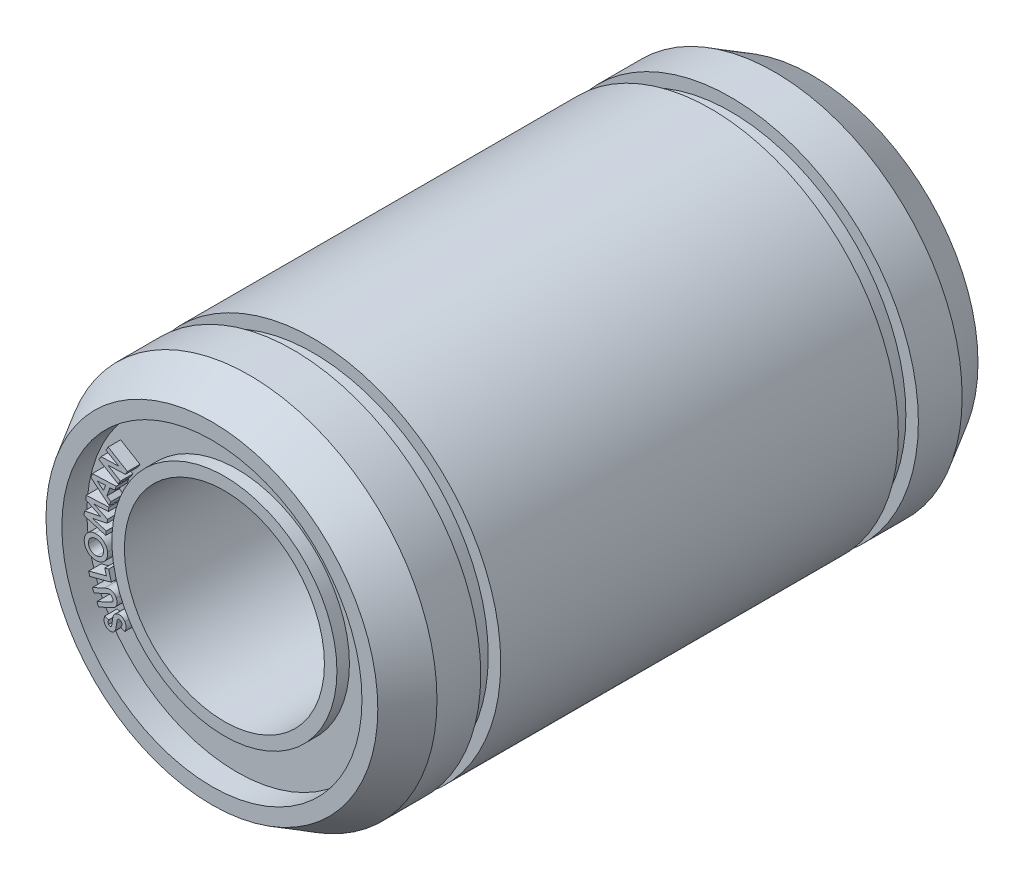
from build123d import *

# Parameters (mm, degrees)
SKETCH1_R                = 7.5
SKETCH1_R_2              = 6
BOSS_EXTRUDE1_DEPTH      = 12
CHAMFER2_SIZE            = 1.5
CHAMFER2_SIZE2           = 0.866025404
SKETCH5_R                = 6
SKETCH5_R_2              = 4
BOSS_EXTRUDE2_DEPTH      = 11
BOSS_EXTRUDE2_DEPTH_BACK = 11
SKETCH6_R                = 4.5
SKETCH6_R_2              = 4
BOSS_EXTRUDE3_DEPTH      = 0.5
SKETCH7_W                = 0.8
SKETCH7_H                = 0.5
BOSS_EXTRUDE4_DEPTH      = 0.5
CHAMFER3_SIZE            = 1.5
CHAMFER3_SIZE2           = 0.866025404


with BuildPart() as part:
    # Sketch1 → Boss-Extrude1 (new, symmetric)
    with BuildSketch(Plane.XY):
        Circle(SKETCH1_R)
        Circle(SKETCH1_R_2, mode=Mode.SUBTRACT)
    extrude(amount=BOSS_EXTRUDE1_DEPTH, both=True)

    # Chamfer2
    chamfer2_edges = [part.edges().sort_by_distance(p)[0] for p in [
        (-7.5, 0, 12),
    ]]
    chamfer2_side = [part.faces().sort_by_distance(p)[0] for p in [
        (-7.5, 0, 0),
    ]]
    chamfer(chamfer2_edges, length=CHAMFER2_SIZE, length2=CHAMFER2_SIZE2, reference=chamfer2_side[0])



with BuildPart() as body_2:
    # Sketch5 → Boss-Extrude2 (new, two sides)
    with BuildSketch(Plane.XY) as boss_extrude2_sk:
        Circle(SKETCH5_R)
        Circle(SKETCH5_R_2, mode=Mode.SUBTRACT)
    extrude(amount=BOSS_EXTRUDE2_DEPTH)
    extrude(boss_extrude2_sk.sketch, amount=-BOSS_EXTRUDE2_DEPTH_BACK)


with BuildPart() as part_1:
    add(part.part)

    add(body_2.part)  # Boss-Extrude3 merges body 2
    # Sketch6 → Boss-Extrude3 (add)
    with BuildSketch(Plane.XY.offset(11)):
        Circle(SKETCH6_R)
        Circle(SKETCH6_R_2, mode=Mode.SUBTRACT)
    boss_extrude3 = extrude(amount=BOSS_EXTRUDE3_DEPTH)

    # Mirror1: Boss-Extrude3 across plane
    add(boss_extrude3.mirror(Plane.XY))

    # Sketch7 → Cut-Revolve1 (revolve, cut)
    with BuildSketch(Plane(origin=(0, 0, 0), x_dir=(0, 0, -1), z_dir=(1, 0, 0)), mode=Mode.PRIVATE) as cut_revolve1_sk:
        with Locations((-8.35, 7.25)):
            Rectangle(SKETCH7_W, SKETCH7_H)
        with Locations((8.35, 7.25)):
            Rectangle(SKETCH7_W, SKETCH7_H)
    revolve(cut_revolve1_sk.sketch.rotate(Axis((0, 0, 0), (0, 0, -1)), 90), axis=Axis((0, 0, 0), (0, 0, -1)), mode=Mode.SUBTRACT)

    # Sketch8 → Boss-Extrude4 (add)
    with BuildSketch(Plane.XY.offset(11)):
        Polygon((-5.019213926, 2.56696334), (-4.934838926, 2.707408052), (-4.229009599, 2.73336959), (-4.736161041, 3.03805709), (-4.647819695, 3.184811898), (-3.877086522, 2.72165084), (-3.961822099, 2.580665263), (-4.666028829, 2.554523436), (-4.160319695, 2.25055709), (-4.248480752, 2.103802283), align=None)
        Polygon((-5.335912282, 1.78586355), (-5.281104589, 1.949024608), (-4.326296897, 1.9897698), (-4.382546897, 1.822462108), (-4.578881032, 1.815070281), (-4.694986801, 1.470178454), (-4.54390507, 1.342714512), (-4.600335359, 1.175406819), align=None)
        Polygon((-5.084049301, 1.793255377), (-4.831645455, 1.582858742), (-4.756104589, 1.807498166), align=None, mode=Mode.SUBTRACT)
        Polygon((-5.614467681, 0.334474611), (-5.594455662, 0.499618842), (-4.951006143, 0.629787111), (-5.544515758, 0.912479419), (-5.524684028, 1.0752799), (-4.619816239, 1.1174674), (-4.639467681, 0.954666919), (-5.210982104, 0.927263073), (-4.673902778, 0.670892881), (-4.691931624, 0.521974611), (-5.274443643, 0.403344804), (-4.726186431, 0.23856115), (-4.746018162, 0.073957785), align=None)
        with BuildLine():
            add(Edge.make_bspline(
                [(-5.603687751, -0.569841462), (-5.604771213, -0.554405134), (-5.606912505, -0.523897658), (-5.604836323, -0.478508597), (-5.59828654, -0.434375331), (-5.587500583, -0.391434334), (-5.572018329, -0.349792704), (-5.552227666, -0.309321337), (-5.527970554, -0.270163036), (-5.499603183, -0.232735486), (-5.46801183, -0.197899174), (-5.433869548, -0.166445264), (-5.39720005, -0.139279288), (-5.358297061, -0.116022804), (-5.316953038, -0.097101922), (-5.27344981, -0.082048667), (-5.227654972, -0.071116249), (-5.196164785, -0.067200484), (-5.180190155, -0.065214058)],
                knots=[0, 0, 0, 0, 1.013293411, 2.002615178, 2.969929983, 3.932617152, 4.898167076, 5.875568108, 6.879846568, 7.911542323, 8.948552327, 9.957490501, 10.948237499, 11.933530897, 12.921966733, 13.921943731, 14.945824639, 16, 16, 16, 16], degree=3))
            add(Edge.make_bspline(
                [(-5.180190155, -0.065214058), (-5.164273478, -0.064064367), (-5.132930459, -0.061800403), (-5.086362342, -0.063759752), (-5.04126119, -0.069851147), (-4.997576001, -0.080239792), (-4.955530926, -0.095487507), (-4.914737099, -0.114512303), (-4.875636997, -0.138461127), (-4.838306799, -0.166172433), (-4.803561242, -0.197027873), (-4.772554477, -0.230566202), (-4.745498007, -0.266182305), (-4.722630215, -0.304154469), (-4.703816933, -0.344353118), (-4.689061103, -0.386768614), (-4.677976192, -0.431298182), (-4.674221861, -0.46197409), (-4.672317559, -0.47753377)],
                knots=[0, 0, 0, 0, 1.051083948, 2.069787806, 3.065186475, 4.047001297, 5.02295037, 6.008083167, 7.00866935, 8.039292488, 9.068841912, 10.066672639, 11.045005907, 12.011619095, 12.982628744, 13.964723154, 14.967650608, 16, 16, 16, 16], degree=3))
            add(Edge.make_bspline(
                [(-4.672317559, -0.47753377), (-4.671174586, -0.493870455), (-4.668931316, -0.525933852), (-4.670769912, -0.573546861), (-4.677277083, -0.619372172), (-4.688096233, -0.663651894), (-4.703679977, -0.706136439), (-4.723860037, -0.746959035), (-4.748544058, -0.786081785), (-4.777419269, -0.823037218), (-4.80937336, -0.857226715), (-4.843868735, -0.887740214), (-4.88035879, -0.914362069), (-4.918952156, -0.936996103), (-4.959495616, -0.955734288), (-5.002160222, -0.970036057), (-5.046713009, -0.980983345), (-5.077372214, -0.984754616), (-5.092930539, -0.986668385)],
                knots=[0, 0, 0, 0, 1.067921877, 2.095970056, 3.101855708, 4.083271722, 5.064468398, 6.04820796, 7.049037107, 8.077279679, 9.103666541, 10.098115712, 11.077681476, 12.046047685, 13.012753385, 13.986115716, 14.978033957, 16, 16, 16, 16], degree=3))
            add(Edge.make_bspline(
                [(-5.092930539, -0.986668385), (-5.103440225, -0.987549711), (-5.124315146, -0.989300249), (-5.155518994, -0.989084084), (-5.186291796, -0.98739402), (-5.216584291, -0.983569235), (-5.246438089, -0.977877368), (-5.27570031, -0.969780851), (-5.304639777, -0.96008789), (-5.333006568, -0.948400159), (-5.360531237, -0.934916184), (-5.386927267, -0.919758882), (-5.411982678, -0.90293231), (-5.435907526, -0.8847182), (-5.458469147, -0.864750233), (-5.479995132, -0.84338628), (-5.499940642, -0.820123157), (-5.518906818, -0.795761388), (-5.536062918, -0.770115503), (-5.551506137, -0.743637034), (-5.565063126, -0.716437945), (-5.576530972, -0.688431306), (-5.586401303, -0.659880537), (-5.594084129, -0.630511219), (-5.600166523, -0.600485556), (-5.60251129, -0.580079819), (-5.603687751, -0.569841462)],
                knots=[0, 0, 0, 0, 1.035459586, 2.056687238, 3.061940431, 4.061370555, 5.053522074, 6.044461155, 7.041290387, 8.049813999, 9.055656306, 10.04996546, 11.037205352, 12.018337724, 13.001244298, 13.994676931, 14.994804129, 16.009047072, 17.025760685, 18.023026782, 19.018281714, 20.008182895, 20.993833169, 21.983241407, 22.988113225, 24, 24, 24, 24], degree=3))
        make_face()
        with BuildLine():
            add(Edge.make_bspline(
                [(-5.438363232, -0.555418385), (-5.437109991, -0.56542628), (-5.434635251, -0.585188591), (-5.427702433, -0.613871064), (-5.418345203, -0.641069143), (-5.406333875, -0.666765442), (-5.391693108, -0.690881294), (-5.374628984, -0.713670472), (-5.354831507, -0.73477848), (-5.332804641, -0.754270174), (-5.309004915, -0.771782064), (-5.283518565, -0.786370216), (-5.257066622, -0.798642664), (-5.229157567, -0.807540183), (-5.200229098, -0.814186762), (-5.17001231, -0.817634244), (-5.138634587, -0.8186527), (-5.117443874, -0.817092034), (-5.106632462, -0.816295789)],
                knots=[0, 0, 0, 0, 1.025341516, 2.024713326, 2.995229938, 3.946946593, 4.904144855, 5.86024931, 6.837787205, 7.84247362, 8.848795365, 9.837565654, 10.825144666, 11.809141188, 12.811705142, 13.839903807, 14.897928127, 16, 16, 16, 16], degree=3))
            add(Edge.make_bspline(
                [(-5.106632462, -0.816295789), (-5.094688186, -0.814876318), (-5.071357327, -0.812103652), (-5.037791139, -0.803591024), (-5.006435982, -0.79230769), (-4.97728422, -0.777790978), (-4.950457703, -0.759978865), (-4.925825447, -0.739127438), (-4.903370801, -0.715235806), (-4.890736526, -0.697230872), (-4.884336789, -0.688110693)],
                knots=[0, 0, 0, 0, 1.084699738, 2.118753527, 3.117445896, 4.087776396, 5.050618586, 6.016709792, 6.995388641, 8, 8, 8, 8], degree=3))
            add(Edge.make_bspline(
                [(-4.884336789, -0.688110693), (-4.879633984, -0.680737899), (-4.87030368, -0.666110374), (-4.858832239, -0.643017012), (-4.849614103, -0.619390583), (-4.842285505, -0.595305786), (-4.83729953, -0.570611441), (-4.834330005, -0.545346552), (-4.833832575, -0.519573391), (-4.835047054, -0.502287849), (-4.835658905, -0.493579443)],
                knots=[0, 0, 0, 0, 1.0250378, 2.03366143, 3.017882375, 3.996738852, 4.982271152, 5.968408103, 6.976489846, 8, 8, 8, 8], degree=3))
            add(Edge.make_bspline(
                [(-4.835658905, -0.493579443), (-4.836906654, -0.483749988), (-4.839363019, -0.464399361), (-4.84634976, -0.436327726), (-4.855726822, -0.40959654), (-4.867830046, -0.384235765), (-4.882745446, -0.360417589), (-4.899997546, -0.337834817), (-4.919916871, -0.316674105), (-4.942360253, -0.297249768), (-4.966398736, -0.27966293), (-4.991804807, -0.264820492), (-5.018151751, -0.252584925), (-5.045580114, -0.243199032), (-5.074056147, -0.236719433), (-5.103450437, -0.232969313), (-5.133885289, -0.231742621), (-5.154415335, -0.233334196), (-5.164865636, -0.234144347)],
                knots=[0, 0, 0, 0, 1.017887162, 2.003850259, 2.967177827, 3.926057472, 4.886110667, 5.851180024, 6.843317752, 7.867950975, 8.898582717, 9.900958706, 10.887792445, 11.880295583, 12.875429553, 13.88465529, 14.923237292, 16, 16, 16, 16], degree=3))
            add(Edge.make_bspline(
                [(-5.164865636, -0.234144347), (-5.175177538, -0.235378278), (-5.195556346, -0.237816824), (-5.225083961, -0.245034804), (-5.253250277, -0.254364368), (-5.279929347, -0.266311679), (-5.305069751, -0.280944867), (-5.328571474, -0.298307051), (-5.350953649, -0.317737921), (-5.371205801, -0.339857601), (-5.389570042, -0.363408286), (-5.405114325, -0.388281309), (-5.418110238, -0.413903596), (-5.427789943, -0.440644009), (-5.43493097, -0.468100528), (-5.438973689, -0.496508494), (-5.440644379, -0.525747181), (-5.439129834, -0.545447083), (-5.438363232, -0.555418385)],
                knots=[0, 0, 0, 0, 1.060114784, 2.095042534, 3.098761831, 4.088032384, 5.075720515, 6.064228771, 7.069149004, 8.098745803, 9.122891904, 10.115965163, 11.090650134, 12.052097306, 13.015502621, 13.983591319, 14.979374611, 16, 16, 16, 16], degree=3))
        make_face(mode=Mode.SUBTRACT)
        Polygon((-5.383854115, -1.663157535), (-5.427303634, -1.499095035), (-4.721834884, -1.312496478), (-4.784935845, -1.073433978), (-4.628445461, -1.03214792), (-4.52189498, -1.43527292), align=None)
        with BuildLine():
            Line((-5.029590563, -2.546195895), (-5.100443928, -2.391147818))
            Line((-5.100443928, -2.391147818), (-4.574722774, -2.150462722))
            add(Edge.make_bspline(
                [(-4.574722774, -2.150462722), (-4.569289345, -2.14798951), (-4.558815687, -2.143222064), (-4.544090686, -2.135519821), (-4.530538579, -2.128410599), (-4.518464239, -2.121442429), (-4.507915492, -2.114515858), (-4.498709107, -2.107843794), (-4.490730338, -2.101500307), (-4.482300342, -2.0929924), (-4.473670766, -2.081933851), (-4.465519588, -2.067443444), (-4.459986373, -2.051630492), (-4.456716618, -2.034751077), (-4.455995341, -2.016996539), (-4.458107291, -1.998623412), (-4.462731902, -1.979697891), (-4.467987538, -1.967464842), (-4.470696332, -1.961159838)],
                knots=[0, 0, 0, 0, 1.148435637, 2.213762344, 3.196639077, 4.093071106, 4.894864287, 5.623441161, 6.280820129, 6.853172085, 7.924131837, 8.969759653, 10.037718811, 11.13305885, 12.267201454, 13.441996364, 14.681586003, 16, 16, 16, 16], degree=3))
            add(Edge.make_bspline(
                [(-4.470696332, -1.961159838), (-4.473890538, -1.95469186), (-4.480123247, -1.942071191), (-4.492098763, -1.925246038), (-4.505810309, -1.910872592), (-4.521146625, -1.899303698), (-4.537241816, -1.889955077), (-4.554057683, -1.883841791), (-4.570990888, -1.880226525), (-4.585535255, -1.879900735), (-4.59784385, -1.88147979), (-4.608665652, -1.883394285), (-4.620897398, -1.88679119), (-4.634696832, -1.89110109), (-4.649886807, -1.896802704), (-4.666740523, -1.903203935), (-4.684899778, -1.911038549), (-4.697448724, -1.916727989), (-4.703989601, -1.919693491)],
                knots=[0, 0, 0, 0, 1.260702351, 2.459950721, 3.597876305, 4.723146205, 5.810989002, 6.842423124, 7.840620339, 8.829355756, 9.369374735, 10.01085573, 10.750578187, 11.588703975, 12.540162428, 13.588874705, 14.743251218, 16, 16, 16, 16], degree=3))
            Line((-4.703989601, -1.919693491), (-5.210239601, -2.151364164))
            Line((-5.210239601, -2.151364164), (-5.281092966, -1.996316088))
            Line((-5.281092966, -1.996316088), (-4.796838159, -1.774741568))
            add(Edge.make_bspline(
                [(-4.796838159, -1.774741568), (-4.787002199, -1.770249768), (-4.768128833, -1.761630844), (-4.740677324, -1.749947873), (-4.715400016, -1.739603126), (-4.692278559, -1.730757846), (-4.671277581, -1.723537479), (-4.652512807, -1.717611222), (-4.635814656, -1.713492866), (-4.616343886, -1.70975109), (-4.592843087, -1.707807506), (-4.564301657, -1.709017842), (-4.534741135, -1.713382083), (-4.504723222, -1.721175851), (-4.475068978, -1.731520901), (-4.447124313, -1.745057493), (-4.421529611, -1.761689769), (-4.397828861, -1.780907568), (-4.376210682, -1.803344675), (-4.356570675, -1.829023034), (-4.338324758, -1.857779444), (-4.328235933, -1.878773275), (-4.323040082, -1.889585318)],
                knots=[0, 0, 0, 0, 1.156467227, 2.219044284, 3.19063233, 4.077593984, 4.866278595, 5.565676642, 6.181452405, 6.704620806, 7.685182106, 8.695051312, 9.754045282, 10.874919227, 12.007289428, 13.108286134, 14.186935546, 15.265086923, 16.365126346, 17.510645842, 18.717956423, 20, 20, 20, 20], degree=3))
            add(Edge.make_bspline(
                [(-4.323040082, -1.889585318), (-4.319801328, -1.896871672), (-4.313434639, -1.911195066), (-4.305953035, -1.933203542), (-4.299750607, -1.954962501), (-4.295207261, -1.976652085), (-4.292385042, -1.998169052), (-4.290778888, -2.019549108), (-4.291283555, -2.040824036), (-4.293001205, -2.061854624), (-4.296324324, -2.082301885), (-4.300584096, -2.102084919), (-4.306191241, -2.120920755), (-4.312821006, -2.139016438), (-4.321041422, -2.156007237), (-4.329987345, -2.172392), (-4.340326118, -2.187761082), (-4.352126497, -2.202486529), (-4.365896988, -2.217076315), (-4.382697228, -2.23143878), (-4.402398465, -2.246142353), (-4.425048855, -2.261363324), (-4.450835444, -2.276714937), (-4.479570666, -2.292596523), (-4.511280755, -2.308851729), (-4.533698655, -2.319232653), (-4.545335755, -2.324621376)],
                knots=[0, 0, 0, 0, 1.021687439, 2.008416554, 2.976688021, 3.921003407, 4.846015211, 5.757160507, 6.666349574, 7.570990458, 8.460113649, 9.319951496, 10.163377453, 10.977587415, 11.787412014, 12.580575583, 13.369010973, 14.15827396, 14.99746724, 15.936709606, 16.987520732, 18.147742274, 19.433275887, 20.833286212, 22.356163382, 24, 24, 24, 24], degree=3))
            Line((-4.545335755, -2.324621376), (-5.029590563, -2.546195895))
        make_face()
        with BuildLine():
            Line((-4.787625882, -2.738342648), (-4.626808575, -2.785037359))
            add(Edge.make_bspline(
                [(-4.626808575, -2.785037359), (-4.630039746, -2.793532567), (-4.636232402, -2.809813939), (-4.64347801, -2.833912043), (-4.647777727, -2.856649193), (-4.649858399, -2.877890845), (-4.649719139, -2.897731914), (-4.646561965, -2.916038457), (-4.64127534, -2.93306829), (-4.635586786, -2.943173498), (-4.632758094, -2.948198417)],
                knots=[0, 0, 0, 0, 1.287646441, 2.467820929, 3.559995072, 4.560638573, 5.488925283, 6.361033311, 7.185006807, 8, 8, 8, 8], degree=3))
            add(Edge.make_bspline(
                [(-4.632758094, -2.948198417), (-4.62969369, -2.952559671), (-4.623792319, -2.960958489), (-4.613215622, -2.971687116), (-4.601362692, -2.979713783), (-4.588725544, -2.985116997), (-4.576059039, -2.988014657), (-4.563988161, -2.988488022), (-4.55270236, -2.986423754), (-4.546210831, -2.982932027), (-4.54297444, -2.981191205)],
                knots=[0, 0, 0, 0, 1.209333939, 2.328912064, 3.400275986, 4.439778179, 5.433183311, 6.334452776, 7.169631329, 8, 8, 8, 8], degree=3))
            add(Edge.make_bspline(
                [(-4.54297444, -2.981191205), (-4.539931765, -2.979080792), (-4.533802346, -2.974829399), (-4.526330581, -2.966310157), (-4.519811242, -2.956663669), (-4.516771723, -2.949404263), (-4.515210017, -2.945674378)],
                knots=[0, 0, 0, 0, 0.965706043, 1.94539934, 2.94434582, 4, 4, 4, 4], degree=3))
            add(Edge.make_bspline(
                [(-4.515210017, -2.945674378), (-4.514147421, -2.94250127), (-4.511686487, -2.935152464), (-4.508626269, -2.922343641), (-4.50514618, -2.906365992), (-4.501689771, -2.887150605), (-4.497638974, -2.864759776), (-4.493548222, -2.839146511), (-4.489215751, -2.81029991), (-4.486402262, -2.789968381), (-4.484921555, -2.779268128)],
                knots=[0, 0, 0, 0, 0.474147896, 1.09810967, 1.865028906, 2.792315478, 3.86513017, 5.090549847, 6.468789568, 8, 8, 8, 8], degree=3))
            add(Edge.make_bspline(
                [(-4.484921555, -2.779268128), (-4.483543698, -2.769291569), (-4.480928684, -2.750357218), (-4.477150431, -2.72349295), (-4.473709848, -2.699697127), (-4.470704208, -2.678885147), (-4.467800185, -2.661107889), (-4.465288031, -2.646322082), (-4.463179715, -2.634590412), (-4.461737628, -2.627823196), (-4.461123479, -2.624941205)],
                knots=[0, 0, 0, 0, 1.547656545, 2.937272422, 4.168857191, 5.242424632, 6.168553879, 6.936782392, 7.547201889, 8, 8, 8, 8], degree=3))
            add(Edge.make_bspline(
                [(-4.461123479, -2.624941205), (-4.458298319, -2.613592032), (-4.452873573, -2.591799853), (-4.442220097, -2.561289002), (-4.430123243, -2.534190823), (-4.416532304, -2.5100363), (-4.400526884, -2.48871582), (-4.382514412, -2.469211495), (-4.362143587, -2.451470655), (-4.347055137, -2.441313209), (-4.339428767, -2.436179186)],
                knots=[0, 0, 0, 0, 1.214063191, 2.331190279, 3.350760311, 4.292816532, 5.202738135, 6.112488508, 7.045968226, 8, 8, 8, 8], degree=3))
            add(Edge.make_bspline(
                [(-4.339428767, -2.436179186), (-4.331765282, -2.431566124), (-4.316698264, -2.422496479), (-4.292869746, -2.411920052), (-4.268935023, -2.403732464), (-4.244704284, -2.398214404), (-4.220210568, -2.395567277), (-4.195437121, -2.395339125), (-4.170408316, -2.397896218), (-4.145458135, -2.40322905), (-4.120795223, -2.410632429), (-4.097110067, -2.42086665), (-4.074421714, -2.4332733), (-4.053088434, -2.448425069), (-4.032815468, -2.465811125), (-4.013635442, -2.48560396), (-3.995532081, -2.507765105), (-3.984841243, -2.523999272), (-3.979392709, -2.532272936)],
                knots=[0, 0, 0, 0, 1.026385115, 2.017954532, 2.986978708, 3.927947565, 4.865391754, 5.810930593, 6.768234365, 7.748207209, 8.737155171, 9.720403376, 10.705804938, 11.701473004, 12.719540757, 13.768872892, 14.862917019, 16, 16, 16, 16], degree=3))
            add(Edge.make_bspline(
                [(-3.979392709, -2.532272936), (-3.975335985, -2.538952031), (-3.967329814, -2.552133597), (-3.957064358, -2.572494822), (-3.948562385, -2.593078158), (-3.941441548, -2.613687431), (-3.936325653, -2.634537339), (-3.932346018, -2.655396193), (-3.930464316, -2.676463277), (-3.930092306, -2.697671677), (-3.931312542, -2.719085231), (-3.934526669, -2.740808474), (-3.939068368, -2.762986114), (-3.945932471, -2.785377069), (-3.954242987, -2.808122109), (-3.964143884, -2.831309439), (-3.976115677, -2.854701333), (-3.985090766, -2.870173513), (-3.989669152, -2.878066205)],
                knots=[0, 0, 0, 0, 1.02160864, 2.016201527, 2.977964644, 3.932250132, 4.864272877, 5.782947909, 6.706450342, 7.626032442, 8.554968956, 9.507408284, 10.495366222, 11.512279178, 12.566377024, 13.661197181, 14.806926365, 16, 16, 16, 16], degree=3))
            Line((-3.989669152, -2.878066205), (-4.138587421, -2.803607071))
            add(Edge.make_bspline(
                [(-4.138587421, -2.803607071), (-4.133582755, -2.794120167), (-4.124015159, -2.775983723), (-4.112417229, -2.748830444), (-4.104574859, -2.722946313), (-4.100083712, -2.698503155), (-4.0990417, -2.675478579), (-4.101522805, -2.653838261), (-4.107572116, -2.633551687), (-4.114322294, -2.621413092), (-4.117673959, -2.615385917)],
                knots=[0, 0, 0, 0, 1.294139108, 2.474050948, 3.55701427, 4.551437514, 5.4659571, 6.327740533, 7.16967329, 8, 8, 8, 8], degree=3))
            add(Edge.make_bspline(
                [(-4.117673959, -2.615385917), (-4.121691377, -2.609583258), (-4.129466434, -2.59835316), (-4.144006382, -2.584398133), (-4.160307907, -2.573666448), (-4.178043275, -2.566720909), (-4.195877507, -2.562515528), (-4.213205131, -2.562314793), (-4.229610565, -2.56561335), (-4.239227245, -2.570782876), (-4.244056171, -2.573378705)],
                knots=[0, 0, 0, 0, 1.147541826, 2.220879599, 3.261013292, 4.306479152, 5.309019566, 6.229449662, 7.110934592, 8, 8, 8, 8], degree=3))
            add(Edge.make_bspline(
                [(-4.244056171, -2.573378705), (-4.248208864, -2.576358894), (-4.256590621, -2.582374079), (-4.267152451, -2.594397336), (-4.276392611, -2.608502711), (-4.282586099, -2.622292125), (-4.287124428, -2.635033274), (-4.290185534, -2.646852154), (-4.293768302, -2.660420715), (-4.29662375, -2.676136667), (-4.300004924, -2.693699469), (-4.302929776, -2.713328725), (-4.306060093, -2.734894462), (-4.307963476, -2.74993771), (-4.308960017, -2.757813802)],
                knots=[0, 0, 0, 0, 0.910679941, 1.838107835, 2.83878883, 3.914970798, 4.529650626, 5.253867616, 6.095047352, 7.03635736, 8.10625351, 9.29081069, 10.58156821, 12, 12, 12, 12], degree=3))
            add(Edge.make_bspline(
                [(-4.308960017, -2.757813802), (-4.310812684, -2.772787344), (-4.314366538, -2.801510134), (-4.320603495, -2.842719534), (-4.326771342, -2.880322426), (-4.333411112, -2.914301646), (-4.340442989, -2.944593979), (-4.347547504, -2.97134736), (-4.355021185, -2.994505787), (-4.363071849, -3.014349791), (-4.371673121, -3.031786928), (-4.380585477, -3.047808743), (-4.390319652, -3.062657231), (-4.400916787, -3.076240393), (-4.411974689, -3.088915497), (-4.423986676, -3.100220374), (-4.436434696, -3.110725381), (-4.445435713, -3.116672828), (-4.449945594, -3.119652744)],
                knots=[0, 0, 0, 0, 1.804438292, 3.461338615, 4.984471496, 6.361666836, 7.60129831, 8.703234628, 9.671512468, 10.50972676, 11.261925021, 11.995661829, 12.70136834, 13.382829797, 14.0549403, 14.710749838, 15.354032529, 16, 16, 16, 16], degree=3))
            add(Edge.make_bspline(
                [(-4.449945594, -3.119652744), (-4.456484382, -3.123514053), (-4.46942205, -3.131154053), (-4.489866374, -3.140130029), (-4.510753734, -3.146909928), (-4.532164422, -3.151244571), (-4.554050445, -3.153237347), (-4.576395278, -3.152784923), (-4.599224145, -3.150277561), (-4.622263931, -3.1453797), (-4.645031358, -3.138513513), (-4.666694142, -3.129203128), (-4.687250574, -3.118162643), (-4.706598023, -3.105147757), (-4.724783791, -3.090051079), (-4.741636783, -3.072873982), (-4.757518598, -3.053904406), (-4.766722452, -3.040000212), (-4.771399921, -3.032933994)],
                knots=[0, 0, 0, 0, 0.982813431, 1.944597851, 2.884883073, 3.822135214, 4.767817035, 5.725308598, 6.712059204, 7.737882008, 8.771939761, 9.786808029, 10.786307958, 11.790132325, 12.801652171, 13.841872472, 14.903223031, 16, 16, 16, 16], degree=3))
            add(Edge.make_bspline(
                [(-4.771399921, -3.032933994), (-4.777007582, -3.023450382), (-4.788166327, -3.004578842), (-4.800293375, -2.973908669), (-4.80904981, -2.942063658), (-4.81313028, -2.914366124), (-4.814369578, -2.891237454), (-4.813905684, -2.872632028), (-4.812446195, -2.852959356), (-4.80990811, -2.832135447), (-4.8061329, -2.810230667), (-4.800950353, -2.787239061), (-4.79487905, -2.763113202), (-4.790085018, -2.74674093), (-4.787625882, -2.738342648)],
                knots=[0, 0, 0, 0, 1.29640846, 2.57973696, 3.871476734, 5.181293919, 5.869045044, 6.598506678, 7.372391716, 8.192697571, 9.06926154, 9.990121729, 10.969017476, 12, 12, 12, 12], degree=3))
        make_face()
    extrude(amount=BOSS_EXTRUDE4_DEPTH)

    # Chamfer3
    chamfer3_edges = [part_1.edges().sort_by_distance(p)[0] for p in [
        (-7.5, 0, -12),
    ]]
    chamfer3_side = [part_1.faces().sort_by_distance(p)[0] for p in [
        (-7.5, 0, -10.375),
    ]]
    chamfer(chamfer3_edges, length=CHAMFER3_SIZE, length2=CHAMFER3_SIZE2, reference=chamfer3_side[0])


solid = part_1.part
